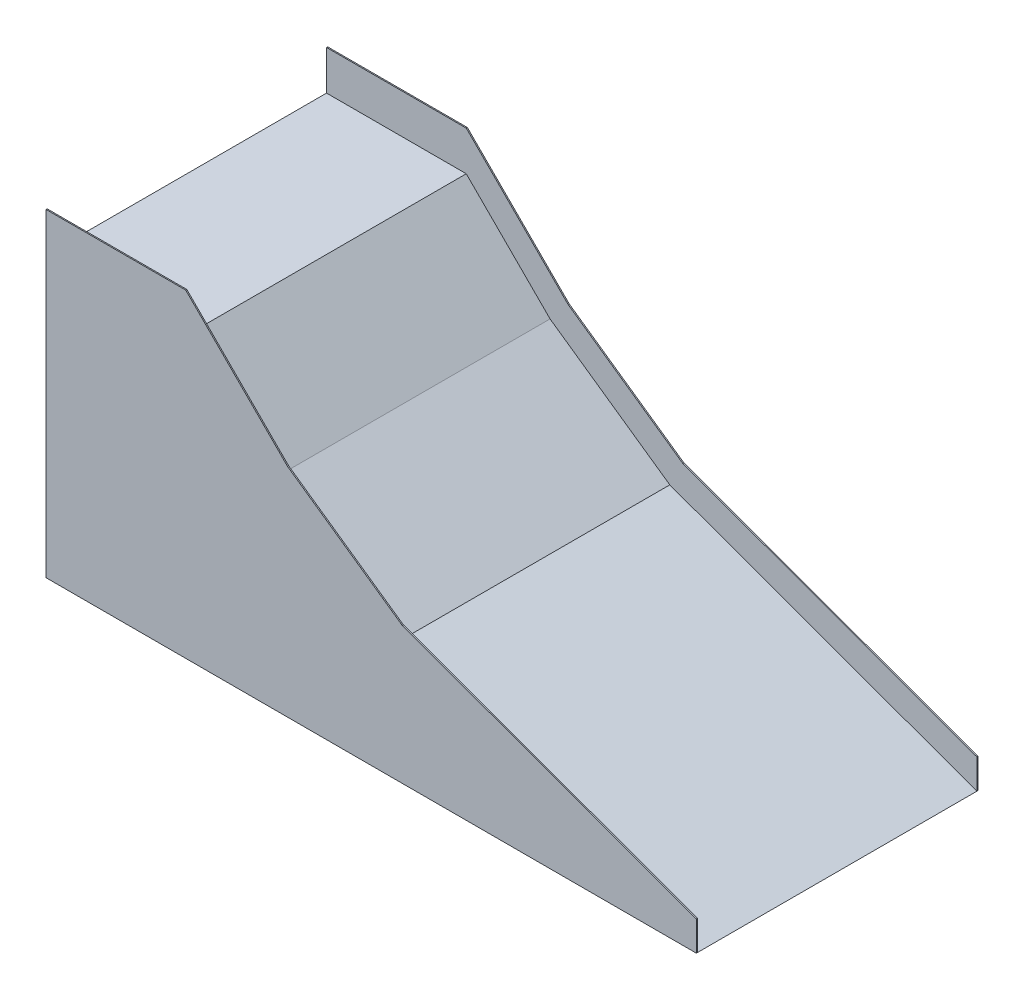
from build123d import *

# Parameters (mm, degrees)
AUFSATZ_LINEAR_AUSTRAGEN1_DEPTH = 500
AUFSATZ_LINEAR_AUSTRAGEN2_DEPTH = 4


with BuildPart() as part:
    # Skizze1 → Aufsatz-Linear austragen1 (new body, symmetric)
    with BuildSketch(Plane.XY):
        Polygon((0, 0), (0, 1000), (500, 1000), (800, 700), (1228.444402023, 400), (2327.435369805, 0), align=None)
    extrude(amount=AUFSATZ_LINEAR_AUSTRAGEN1_DEPTH, both=True)

    # Skizze3 → Aufsatz-Linear austragen2 (add)
    with BuildSketch(Plane.XY.offset(500)):
        Polygon((0, 0), (0, 1141.421356237), (500, 1141.421356237), (864.524295393, 776.897060844), (1275.017704404, 489.466481469), (2327.435369805, 106.417777248), (2327.435369805, 0), align=None)
    aufsatz_linear_austragen2 = extrude(amount=AUFSATZ_LINEAR_AUSTRAGEN2_DEPTH)

    # Spiegeln1: Aufsatz-Linear austragen2 across plane
    add(aufsatz_linear_austragen2.mirror(Plane(origin=(0, 0, 0), x_dir=(1, 0, 0), z_dir=(0, 0, -1))))


solid = part.part
